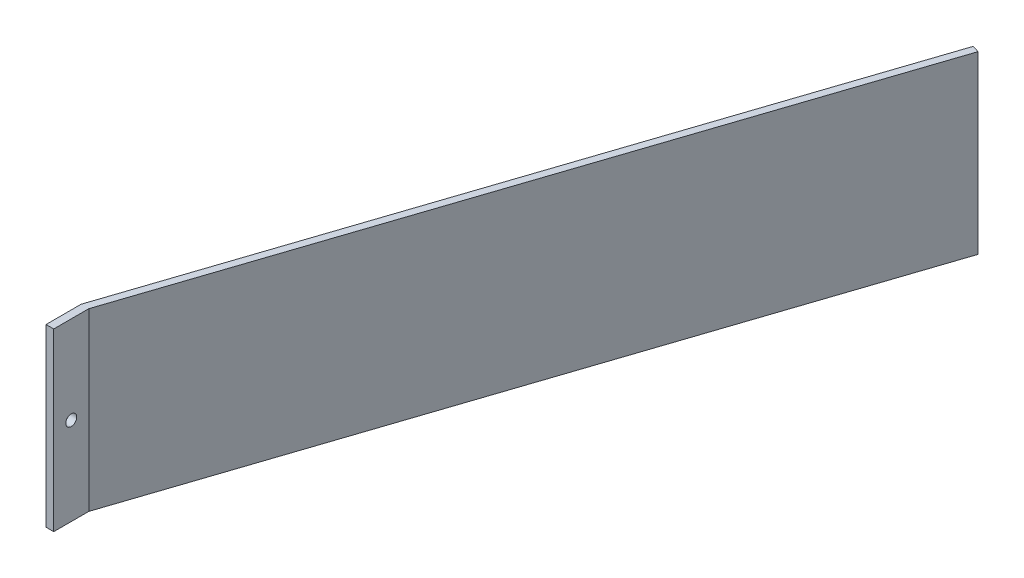
from build123d import *

# Parameters (mm, degrees)
BOSS_EXTRUDE1_DEPTH     = 76.2
SKETCH2_R               = 2.38125
CUT_EXTRUDE1_DEPTH      = 1
CUT_EXTRUDE1_DEPTH_BACK = 100.695


with BuildPart() as part:
    # Sketch1 → Boss-Extrude1 (new body)
    with BuildSketch(Plane(origin=(0, 0, 0), x_dir=(1, 0, 0), z_dir=(0, 1, 0))):
        Polygon((-279.4, -137.16), (-182.717603245, 153.402420415), (-179.705, 152.4), (-276.05384912, -137.16), (-276.05384912, -152.4), (-279.4, -152.4), align=None)
    extrude(amount=BOSS_EXTRUDE1_DEPTH)

    # Sketch2 → Cut-Extrude1 (cut, two sides)
    with BuildSketch(Plane.ZY.offset(279.4)) as cut_extrude1_sk:
        with Locations((144.78, 38.1)):
            Circle(SKETCH2_R)
    extrude(amount=CUT_EXTRUDE1_DEPTH, mode=Mode.SUBTRACT)
    extrude(cut_extrude1_sk.sketch, amount=-CUT_EXTRUDE1_DEPTH_BACK, mode=Mode.SUBTRACT)


solid = part.part
